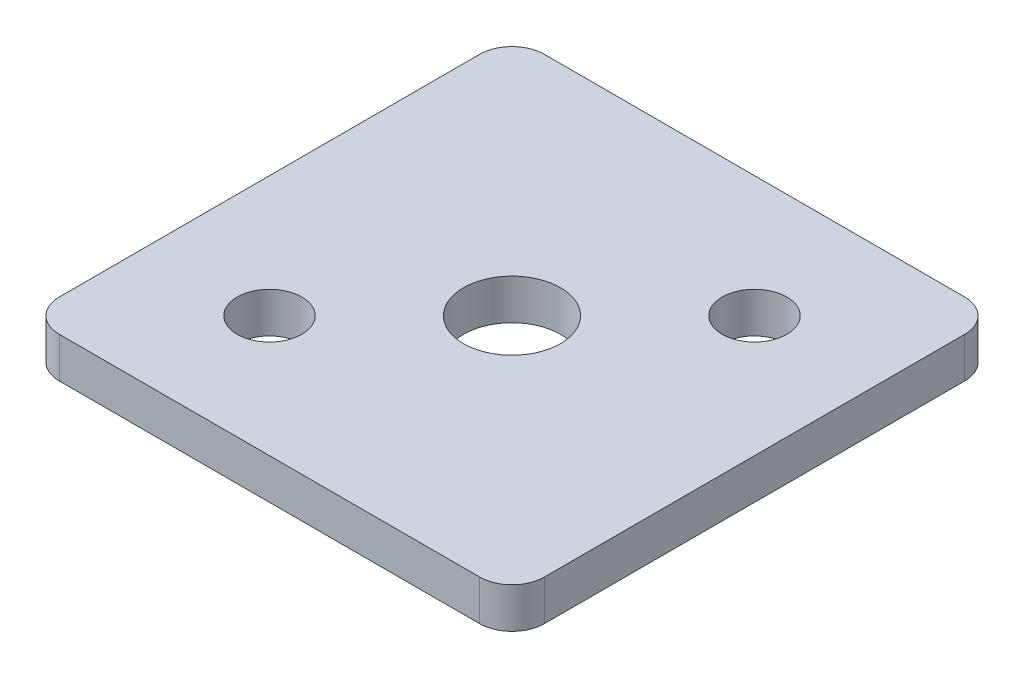
from build123d import *

# Parameters (mm, degrees)
SKETCH1_W           = 38.1
SKETCH1_H           = 38.1
SKETCH1_R           = 2.54
SKETCH1_R_2         = 3.81
BOSS_EXTRUDE1_DEPTH = 3.175
FILLET1_R           = 2.54


with BuildPart() as part:
    # Sketch1 → Boss-Extrude1 (new body)
    with BuildSketch(Plane(origin=(0, 0, 0), x_dir=(1, 0, 0), z_dir=(0, 1, 0))):
        Rectangle(SKETCH1_W, SKETCH1_H)
        with Locations((9.525, 9.525)):
            Circle(SKETCH1_R, mode=Mode.SUBTRACT)
        with Locations((-9.525, -9.525)):
            Circle(SKETCH1_R, mode=Mode.SUBTRACT)
        Circle(SKETCH1_R_2, mode=Mode.SUBTRACT)
    extrude(amount=BOSS_EXTRUDE1_DEPTH)

    # Fillet1
    fillet1_edges = [part.edges().sort_by_distance(p)[0] for p in [
        (-19.05, 1.5875, -19.05),
        (19.05, 1.5875, -19.05),
        (19.05, 1.5875, 19.05),
        (-19.05, 1.5875, 19.05),
    ]]
    fillet(fillet1_edges, radius=FILLET1_R)


solid = part.part
